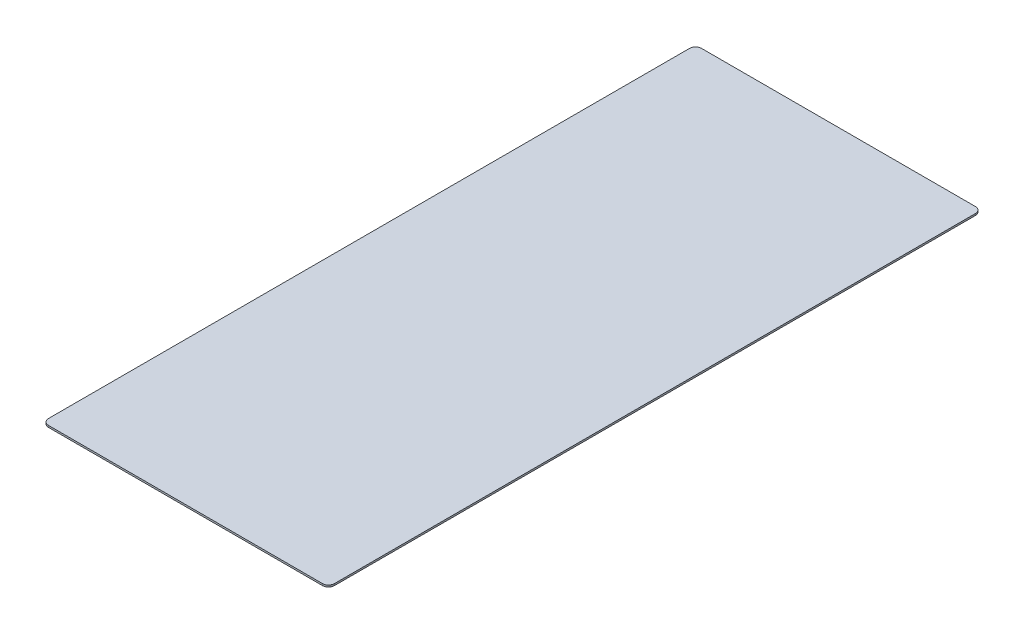
from build123d import *

# Parameters (mm, degrees)
BOSS_EXTRUDE1_DEPTH = 3


with BuildPart() as part:
    # Sketch1 → Boss-Extrude1 (new body)
    with BuildSketch(Plane(origin=(0, 0, 0), x_dir=(1, 0, 0), z_dir=(0, 1, 0))):
        with BuildLine():
            Line((-231.5, -551.5), (231.5, -551.5))
            ThreePointArc((231.5, -551.5), (238.571067812, -548.571067812), (241.5, -541.5))
            Line((241.5, -541.5), (241.5, 541.5))
            ThreePointArc((241.5, 541.5), (238.571067812, 548.571067812), (231.5, 551.5))
            Line((231.5, 551.5), (-231.5, 551.5))
            ThreePointArc((-231.5, 551.5), (-238.571067812, 548.571067812), (-241.5, 541.5))
            Line((-241.5, 541.5), (-241.5, -541.5))
            ThreePointArc((-241.5, -541.5), (-238.571067812, -548.571067812), (-231.5, -551.5))
        make_face()
    extrude(amount=BOSS_EXTRUDE1_DEPTH)


solid = part.part
